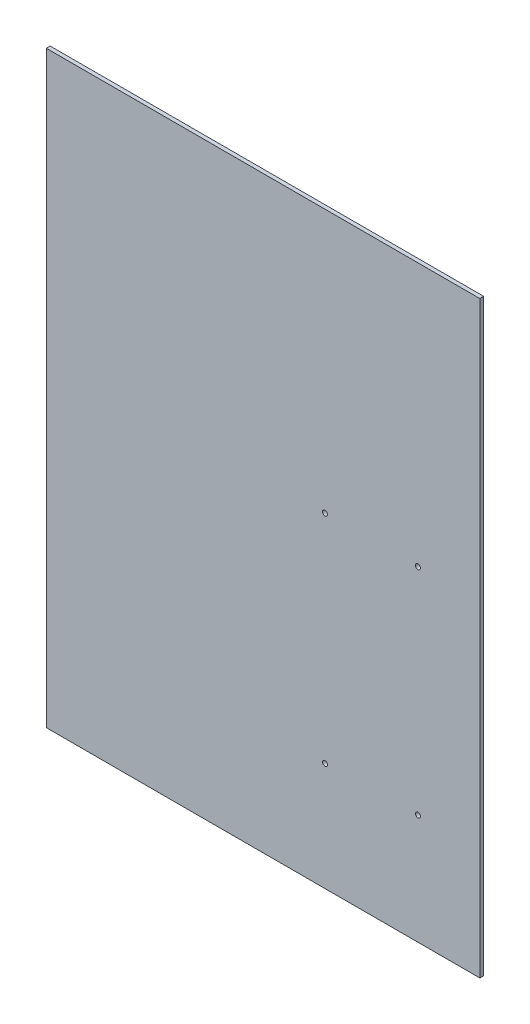
from build123d import *

# Parameters (mm, degrees)
SKETCH1_W                  = 355.6
SKETCH1_H                  = 482.6
EXTRUDE1_DEPTH             = 3.175
F_10_CLEARANCE_HOLE1_D     = 4.0386
F_10_CLEARANCE_HOLE1_DEPTH = 3.175


with BuildPart() as part:
    # Sketch1 → Extrude1 (new body)
    with BuildSketch(Plane.XY):
        with Locations((0, 241.3)):
            Rectangle(SKETCH1_W, SKETCH1_H)
    extrude(amount=EXTRUDE1_DEPTH)

    # #10 Clearance Hole1
    with Locations(Plane(origin=(0, 0, 0), x_dir=(-1, 0, 0), z_dir=(0, 0, -1))):
        with Locations((-126.999855288, 266.7), (-50.799855288, 266.7), (-50.799855288, 88.9), (-126.999855288, 90.332964778)):
            Hole(F_10_CLEARANCE_HOLE1_D / 2, depth=F_10_CLEARANCE_HOLE1_DEPTH)


solid = part.part
